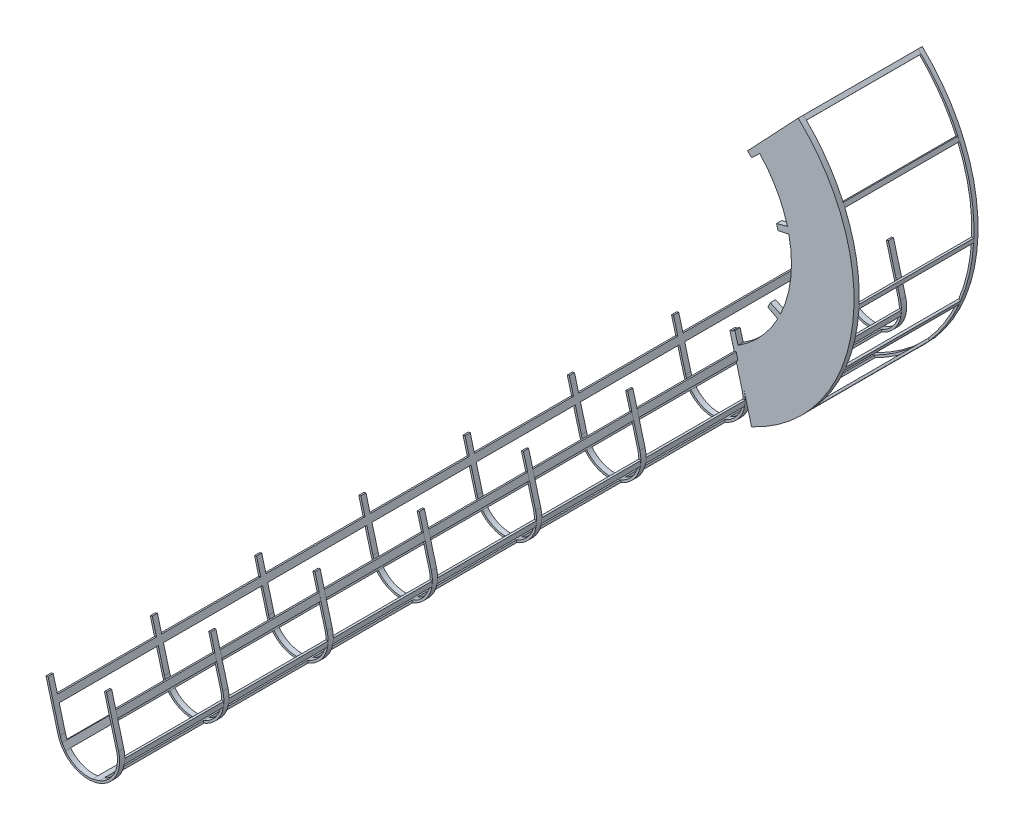
from build123d import *

# Parameters (mm, degrees)
EXTRUDE1_DEPTH      = 50
EXTRUDE2_DEPTH      = 50
EXTRUDE3_DEPTH      = 1500
EXTRUDE3_DEPTH_BACK = 9000
LPATTERN3_COUNT     = 10
LPATTERN3_PITCH     = 1000
LPATTERN4_COUNT     = 2
LPATTERN4_PITCH     = 1500
EXTRUDE4_REACH      = 771.724
SKETCH4_W           = 1450
SKETCH4_H           = 65.629623874
EXTRUDE6_DEPTH      = 1100
EXTRUDE7_DEPTH      = 40
SKETCH11_W          = 1051.11781951
SKETCH11_H          = 1220.96307693
EXTRUDE8_DEPTH      = 3000


with BuildPart() as part:
    # Sketch1 → Extrude1 (new body)
    with BuildSketch(Plane.XY):
        with BuildLine():
            Line((3314.731886983, 2094.985971824), (3126.447589995, 2797.672534452))
            ThreePointArc((3126.447589995, 2797.672534452), (3140.915661979, 2807.05082531), (3155.219891444, 2816.677167593))
            Line((3155.219891444, 2816.677167593), (3184.674464629, 2706.751203952))
            ThreePointArc((3184.674464629, 2706.751203952), (3401.579677973, 2887.431922355), (3565.783580938, 3117.063087116))
            Line((3565.783580938, 3117.063087116), (3470.674831648, 3168.163783949))
            ThreePointArc((3470.674831648, 3168.163783949), (3483.167151586, 3192.189169327), (3495.004365382, 3216.543995739))
            Line((3495.004365382, 3216.543995739), (3592.739910715, 3170.666783676))
            ThreePointArc((3592.739910715, 3170.666783676), (3690.595949959, 3515.847602922), (3673.019311438, 3874.200312091))
            Line((3673.019311438, 3874.200312091), (3567.460831234, 3851.520747165))
            ThreePointArc((3567.460831234, 3851.520747165), (3561.41467612, 3877.916224208), (3554.656037739, 3904.138314271))
            Line((3554.656037739, 3904.138314271), (3658.832017922, 3932.498860124))
            ThreePointArc((3658.832017922, 3932.498860124), (3555.169627188, 4185.152000437), (3392.856745209, 4404.774469476))
            Line((3392.856745209, 4404.774469476), (3314.599085503, 4330.39238759))
            ThreePointArc((3314.599085503, 4330.39238759), (3295.679418909, 4349.765653086), (3276.242126653, 4368.619535173))
            Line((3276.242126653, 4368.619535173), (3762.240436606, 4883.423823812))
            ThreePointArc((3762.240436606, 4883.423823812), (4276.160236026, 3370.817660025), (3314.731886983, 2094.985971824))
        make_face()
    extrude(amount=EXTRUDE1_DEPTH)

    # Sketch2 → Extrude2 (add)
    with BuildSketch(Plane(origin=(0, 0, 0), x_dir=(-1, 0, 0), z_dir=(0, 0, -1))):
        with BuildLine():
            Line((-3126.447589995, 2797.672534452), (-3242.649029714, 2364.002857506))
            ThreePointArc((-3242.649029714, 2364.002857506), (-3030.516995358, 1996.579396089), (-2663.093533941, 2208.711430445))
            Line((-2663.093533941, 2208.711430445), (-2546.892094221, 2642.381107391))
            Line((-2546.892094221, 2642.381107391), (-2566.210610747, 2647.557488293))
            Line((-2566.210610747, 2647.557488293), (-2682.412050467, 2213.887811347))
            ThreePointArc((-2682.412050467, 2213.887811347), (-3025.340614456, 2015.897912615), (-3223.330513188, 2358.826476604))
            Line((-3223.330513188, 2358.826476604), (-3107.129073469, 2792.49615355))
            Line((-3107.129073469, 2792.49615355), (-3126.447589995, 2797.672534452))
        make_face()
    extrude2 = extrude(amount=-EXTRUDE2_DEPTH)

    # Sketch3 → Extrude3 (add, two sides)
    with BuildSketch(Plane(origin=(0, 0, 0), x_dir=(-1, 0, 0), z_dir=(0, 0, -1))) as extrude3_sk:
        Polygon((-2587.64493608, 2490.28943102), (-2604.631132662, 2426.89608235), (-2623.949649188, 2432.072463252), (-2606.963452606, 2495.465811922), align=None)
        Polygon((-3147.881915328, 2640.404477179), (-3164.86811191, 2577.011128509), (-3184.120974762, 2582.169917563), (-3167.13477818, 2645.563266232), align=None)
        Polygon((-3062.405972725, 2007.068491342), (-2997.655783232, 1989.718730357), (-2992.444436678, 2009.167740471), (-3057.194626171, 2026.517501456), align=None)
        Polygon((-2733.40372447, 2112.477900627), (-2701.013772232, 2164.014204414), (-2683.986261942, 2153.31261729), (-2716.376214179, 2101.776313503), align=None)
        Polygon((-3232.871281827, 2286.357143976), (-3227.806146277, 2233.339974018), (-3247.800064954, 2231.429802117), (-3252.865200505, 2284.446972075), align=None)
    extrude(amount=EXTRUDE3_DEPTH)
    extrude(extrude3_sk.sketch, amount=-EXTRUDE3_DEPTH_BACK)

    # LPattern3: Extrude2 ×10
    with Locations(*[(0, 0, i * LPATTERN3_PITCH) for i in range(1, LPATTERN3_COUNT)]):
        add(extrude2)

    # LPattern4: Extrude2 ×2
    with Locations(*[(0, 0, -i * LPATTERN4_PITCH) for i in range(1, LPATTERN4_COUNT)]):
        add(extrude2)

    # Sketch4 → Extrude4 (cut, up to next)
    with BuildSketch(Plane(origin=(3616.367793205, 969.002829723, 0), x_dir=(0, 0, -1), z_dir=(0.965925826, 0.258819045, 0)), mode=Mode.PRIVATE) as extrude4_sk1:
        with Locations((725, 1702.888272999)):
            Rectangle(SKETCH4_W, SKETCH4_H)
    extrude4_tool1 = extrude(extrude4_sk1.sketch, amount=-EXTRUDE4_REACH, mode=Mode.PRIVATE) & part.part
    add(extrude4_tool1.solids().sort_by_distance((3175.627876, 2613.866592, -725))[0], mode=Mode.SUBTRACT)

    # Sketch7 → Extrude6 (add)
    with BuildSketch(Plane(origin=(0, 0, 0), x_dir=(-1, 0, 0), z_dir=(0, 0, -1))):
        Polygon((-3762.240436606, 4883.423823812), (-3791.003232776, 4855.626313915), (-3777.104477828, 4841.24491583), (-3748.341681657, 4869.042425727), align=None)
        Polygon((-4143.896974264, 4349.874198512), (-4160.06041564, 4313.285359191), (-4141.765995979, 4305.203638503), (-4125.602554603, 4341.792477824), align=None)
        Polygon((-4296.572183201, 3578.323205217), (-4294.622672169, 3538.323205217), (-4274.646383643, 3539.296805089), (-4276.595894675, 3579.296805089), align=None)
        Polygon((-4170.804363373, 2995.326747317), (-4153.860411873, 2955.326747317), (-4135.444517377, 2963.127697896), (-4152.388468877, 3003.127697896), align=None)
        Polygon((-3871.481735696, 2512.579910573), (-3844.694043369, 2482.874363284), (-3829.841269724, 2496.268209447), (-3856.628962051, 2525.973756737), align=None)
        Polygon((-3314.731886983, 2094.985971824), (-3350.748504069, 2112.387215851), (-3342.047882056, 2130.395524394), (-3306.03126497, 2112.994280367), align=None)
    extrude(amount=EXTRUDE6_DEPTH)

    # Sketch10 → Extrude7 (add)
    with BuildSketch(Plane(origin=(0, 0, -1100), x_dir=(-1, 0, 0), z_dir=(0, 0, -1))):
        with BuildLine():
            Line((-3276.242126653, 4368.619535173), (-3762.240436606, 4883.423823812))
            ThreePointArc((-3762.240436606, 4883.423823812), (-4276.160236026, 3370.817660025), (-3314.731886983, 2094.985971824))
            Line((-3314.731886983, 2094.985971824), (-3306.242735656, 2113.094928441))
            ThreePointArc((-3306.242735656, 2113.094928441), (-4254.799055144, 3364.11771616), (-3762.972862584, 4855.065100525))
            Line((-3762.972862584, 4855.065100525), (-3290.785290711, 4354.890136819))
            Line((-3290.785290711, 4354.890136819), (-3276.242126653, 4368.619535173))
        make_face()
    extrude(amount=EXTRUDE7_DEPTH)

    # Sketch11 → Extrude8 (cut)
    with BuildSketch(Plane.XY.offset(9050)):
        with Locations((2821.448186209, 2390.163389693)):
            Rectangle(SKETCH11_W, SKETCH11_H)
    extrude(amount=-EXTRUDE8_DEPTH, mode=Mode.SUBTRACT)


solid = part.part
